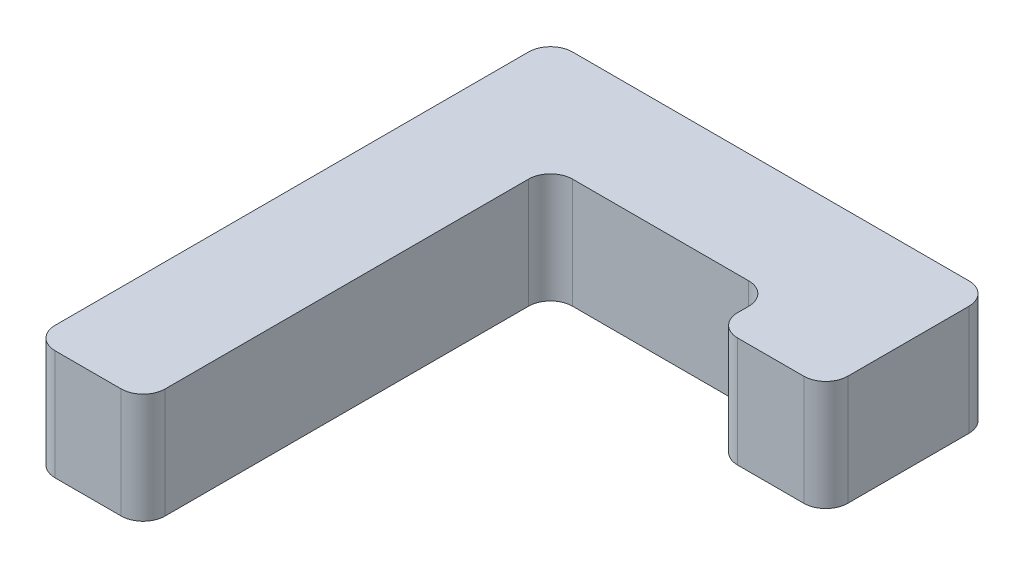
from build123d import *

# Parameters (mm, degrees)
BOSS_EXTRUDE1_DEPTH = 12.7
FILLET1_R           = 2.54


with BuildPart() as part:
    # Sketch1 → Boss-Extrude1 (new body)
    with BuildSketch(Plane(origin=(0, 0, 0), x_dir=(1, 0, 0), z_dir=(0, 1, 0))):
        Polygon((0, 0), (0, 59.69), (50.8, 59.69), (50.8, 40.64), (38.1, 40.64), (38.1, 46.99), (12.7, 46.99), (12.7, 0), align=None)
    extrude(amount=BOSS_EXTRUDE1_DEPTH)

    # Fillet1
    fillet1_edges = [part.edges().sort_by_distance(p)[0] for p in [
        (0, 6.35, 0),
        (0, 6.35, -59.69),
        (50.8, 6.35, -59.69),
        (50.8, 6.35, -40.64),
        (38.1, 6.35, -40.64),
        (38.1, 6.35, -46.99),
        (12.7, 6.35, -46.99),
        (12.7, 6.35, 0),
    ]]
    fillet(fillet1_edges, radius=FILLET1_R)


solid = part.part
